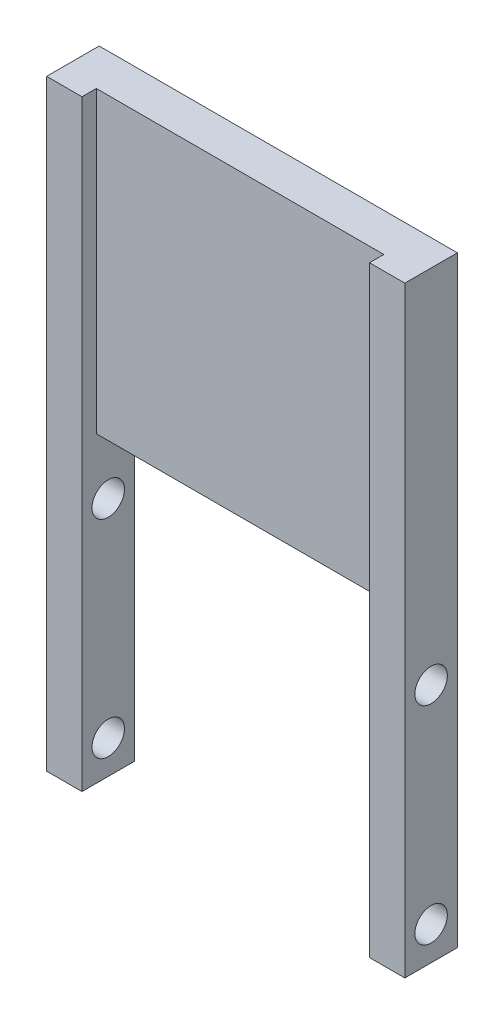
from build123d import *

# Parameters (mm, degrees)
BOSS_EXTRUDE1_DEPTH = 5.5
SKETCH2_W           = 30.1
SKETCH2_H           = 31.3
CUT_EXTRUDE1_DEPTH  = 1.5
SKETCH3_R           = 1.7
CUT_EXTRUDE2_DEPTH  = 38.5


with BuildPart() as part:
    # Sketch1 → Boss-Extrude1 (new body)
    with BuildSketch(Plane.XY):
        Polygon((33.8, 0), (37.5, 0), (37.5, 63), (0, 63), (0, 0), (3.7, 0), (3.7, 31.7), (33.8, 31.7), align=None)
    extrude(amount=-BOSS_EXTRUDE1_DEPTH)

    # Sketch2 → Cut-Extrude1 (cut)
    with BuildSketch(Plane.XY):
        with Locations((18.75, 47.35)):
            Rectangle(SKETCH2_W, SKETCH2_H)
    extrude(amount=-CUT_EXTRUDE1_DEPTH, mode=Mode.SUBTRACT)

    # Sketch3 → Cut-Extrude2 (cut, through all)
    with BuildSketch(Plane(origin=(37.5, 0, 0), x_dir=(0, 0, -1), z_dir=(1, 0, 0))):
        with Locations((2.75, 3.5)):
            Circle(SKETCH3_R)
        with Locations((2.75, 25.2)):
            Circle(SKETCH3_R)
    extrude(amount=-CUT_EXTRUDE2_DEPTH, mode=Mode.SUBTRACT)


solid = part.part
